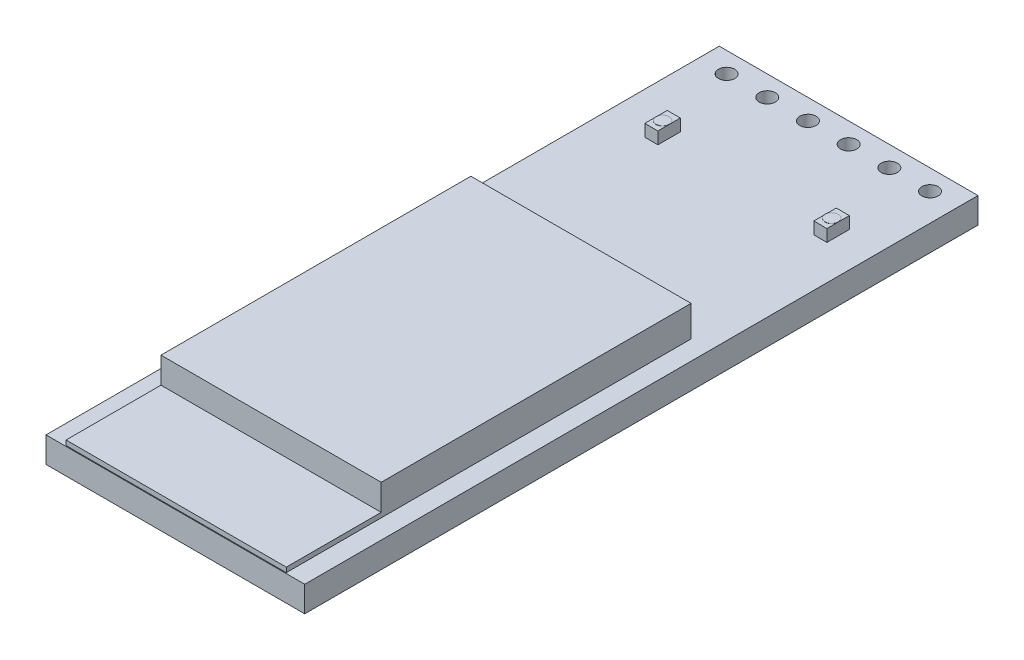
from build123d import *

# Parameters (mm, degrees)
SKETCH1_W           = 16.1544
SKETCH1_H           = 42.037
BOSS_EXTRUDE1_DEPTH = 0.8001
SKETCH2_R           = 0.508
CUT_EXTRUDE1_DEPTH  = 1.6002
SKETCH3_W           = 13.75
SKETCH3_H           = 25.275
BOSS_EXTRUDE2_DEPTH = 0.3
SKETCH4_W           = 13.75
SKETCH4_H           = 19.35
BOSS_EXTRUDE3_DEPTH = 1.625
SKETCH5_W           = 0.82
SKETCH5_H           = 1.4
BOSS_EXTRUDE4_DEPTH = 0.75
SKETCH6_R           = 0.41
BOSS_EXTRUDE5_DEPTH = 0.01


with BuildPart() as part:
    # Sketch1 → Boss-Extrude1 (new body, symmetric)
    with BuildSketch(Plane(origin=(0, 0, 0), x_dir=(1, 0, 0), z_dir=(0, 1, 0))):
        Rectangle(SKETCH1_W, SKETCH1_H)
    extrude(amount=BOSS_EXTRUDE1_DEPTH, both=True)

    # Sketch2 → Cut-Extrude1 (cut)
    with BuildSketch(Plane(origin=(0, 0.8001, 0), x_dir=(1, 0, 0), z_dir=(0, 1, 0))):
        with Locations((-6.35, 19.7485)):
            Circle(SKETCH2_R)
        with Locations((-3.81, 19.7485)):
            Circle(SKETCH2_R)
        with Locations((-1.27, 19.7485)):
            Circle(SKETCH2_R)
        with Locations((1.27, 19.7485)):
            Circle(SKETCH2_R)
        with Locations((3.81, 19.7485)):
            Circle(SKETCH2_R)
        with Locations((6.35, 19.7485)):
            Circle(SKETCH2_R)
    extrude(amount=-CUT_EXTRUDE1_DEPTH, mode=Mode.SUBTRACT)

    # Sketch3 → Boss-Extrude2 (add)
    with BuildSketch(Plane(origin=(0, 0.8001, 0), x_dir=(1, 0, 0), z_dir=(0, 1, 0))):
        with Locations((0, -8.331)):
            Rectangle(SKETCH3_W, SKETCH3_H)
    extrude(amount=BOSS_EXTRUDE2_DEPTH)

    # Sketch4 → Boss-Extrude3 (add)
    with BuildSketch(Plane(origin=(0, 1.1001, 0), x_dir=(1, 0, 0), z_dir=(0, 1, 0))):
        with Locations((0, -5.3685)):
            Rectangle(SKETCH4_W, SKETCH4_H)
    extrude(amount=BOSS_EXTRUDE3_DEPTH)

    # Sketch5 → Boss-Extrude4 (add)
    with BuildSketch(Plane(origin=(0, 0.8001, 0), x_dir=(1, 0, 0), z_dir=(0, 1, 0))):
        with Locations((-5.0672, 14.4685)):
            Rectangle(SKETCH5_W, SKETCH5_H)
        with Locations((5.4872, 14.4685)):
            Rectangle(SKETCH5_W, SKETCH5_H)
    extrude(amount=BOSS_EXTRUDE4_DEPTH)

    # Sketch6 → Boss-Extrude5 (add)
    with BuildSketch(Plane(origin=(0, 1.5501, 0), x_dir=(1, 0, 0), z_dir=(0, 1, 0))):
        with Locations((-5.0672, 14.4685)):
            Circle(SKETCH6_R)
        with Locations((5.4872, 14.4685)):
            Circle(SKETCH6_R)
    extrude(amount=BOSS_EXTRUDE5_DEPTH)


solid = part.part
